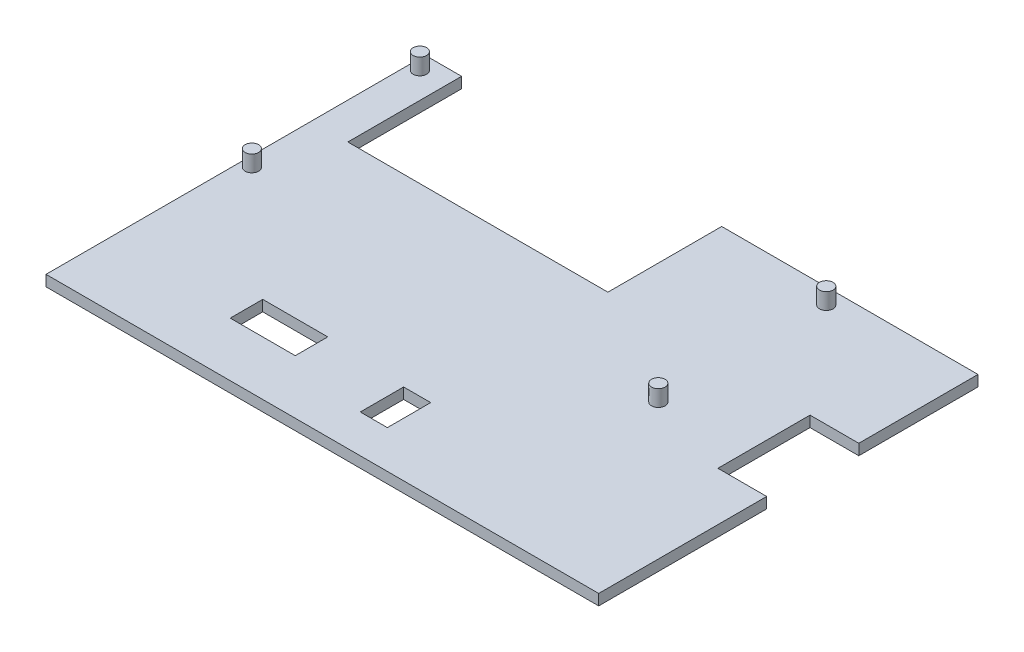
from build123d import *

# Parameters (mm, degrees)
CROQUIS1_W              = 12
CROQUIS1_H              = 6
CROQUIS1_W_2            = 5
CROQUIS1_H_2            = 8
SALIENTE_EXTRUIR1_DEPTH = 2
CROQUIS2_R              = 1.25
SALIENTE_EXTRUIR2_DEPTH = 3


with BuildPart() as part:
    # Croquis1 → Saliente-Extruir1 (new body)
    with BuildSketch(Plane(origin=(0, 0, 0), x_dir=(1, 0, 0), z_dir=(0, 1, 0))):
        Polygon((0, 70), (6.7, 70), (6.7, 49), (54.7, 49), (54.7, 70), (102, 70), (102, 48), (93, 48), (93, 31), (102, 31), (102, 0), (0, 0), align=None)
        with Locations((30, 13)):
            Rectangle(CROQUIS1_W, CROQUIS1_H, mode=Mode.SUBTRACT)
        with Locations((53.5, 11)):
            Rectangle(CROQUIS1_W_2, CROQUIS1_H_2, mode=Mode.SUBTRACT)
    extrude(amount=SALIENTE_EXTRUIR1_DEPTH)

    # Croquis2 → Saliente-Extruir2 (add)
    with BuildSketch(Plane(origin=(0, 2, 0), x_dir=(1, 0, 0), z_dir=(0, 1, 0))):
        with Locations((1.9, 67.1)):
            Circle(CROQUIS2_R)
        with Locations((1.9, 36.1)):
            Circle(CROQUIS2_R)
        with Locations((76.9, 36.1)):
            Circle(CROQUIS2_R)
        with Locations((76.9, 67.1)):
            Circle(CROQUIS2_R)
    extrude(amount=SALIENTE_EXTRUIR2_DEPTH)


solid = part.part
